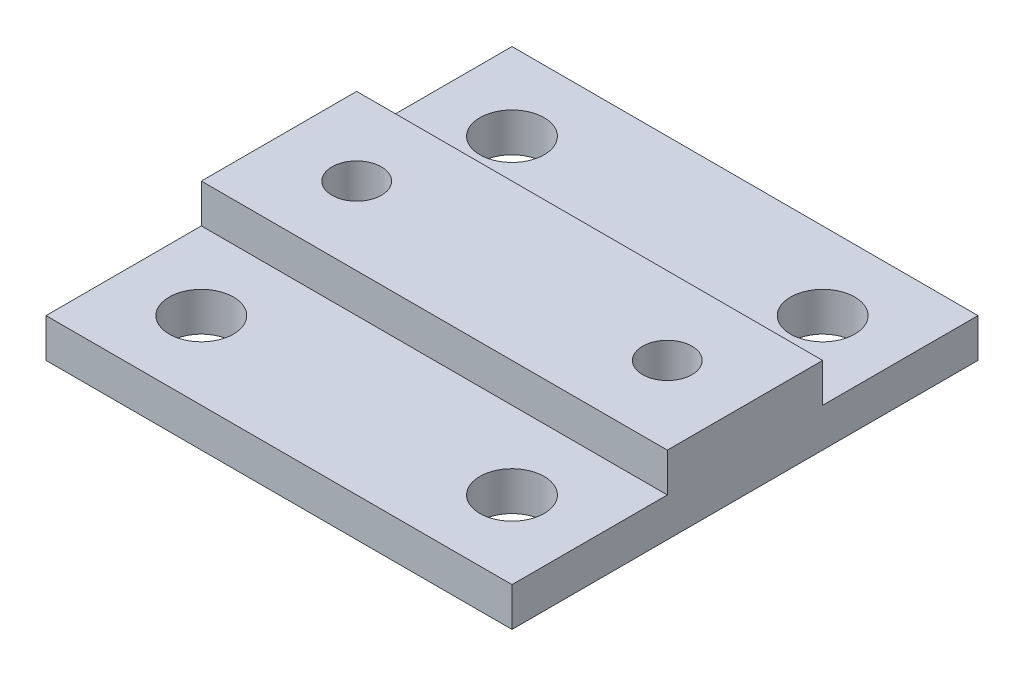
from build123d import *

# Parameters (mm, degrees)
SKETCH1_W           = 38.1
SKETCH1_H           = 38.1
SKETCH1_R           = 2.0193
SKETCH1_R_2         = 2.6289
BOSS_EXTRUDE4_DEPTH = 6.35
SKETCH12_W          = 38.1
SKETCH12_H          = 12.7
CUT_EXTRUDE7_DEPTH  = 3.175


with BuildPart() as part:
    # Sketch1 → Boss-Extrude4 (new body)
    with BuildSketch(Plane(origin=(0, 0, 0), x_dir=(1, 0, 0), z_dir=(0, 1, 0))):
        Rectangle(SKETCH1_W, SKETCH1_H)
        with Locations((-12.7, 0)):
            Circle(SKETCH1_R, mode=Mode.SUBTRACT)
        with Locations((12.7, 0)):
            Circle(SKETCH1_R, mode=Mode.SUBTRACT)
        with Locations((-12.7, 12.7)):
            Circle(SKETCH1_R_2, mode=Mode.SUBTRACT)
        with Locations((12.7, 12.7)):
            Circle(SKETCH1_R_2, mode=Mode.SUBTRACT)
        with Locations((12.7, -12.7)):
            Circle(SKETCH1_R_2, mode=Mode.SUBTRACT)
        with Locations((-12.7, -12.7)):
            Circle(SKETCH1_R_2, mode=Mode.SUBTRACT)
    extrude(amount=BOSS_EXTRUDE4_DEPTH)

    # Sketch12 → Cut-Extrude7 (cut)
    with BuildSketch(Plane(origin=(0, 6.35, 0), x_dir=(1, 0, 0), z_dir=(0, 1, 0))):
        with Locations((0, 12.7)):
            Rectangle(SKETCH12_W, SKETCH12_H)
        with Locations((0, -12.7)):
            Rectangle(SKETCH12_W, SKETCH12_H)
    extrude(amount=-CUT_EXTRUDE7_DEPTH, mode=Mode.SUBTRACT)


solid = part.part
